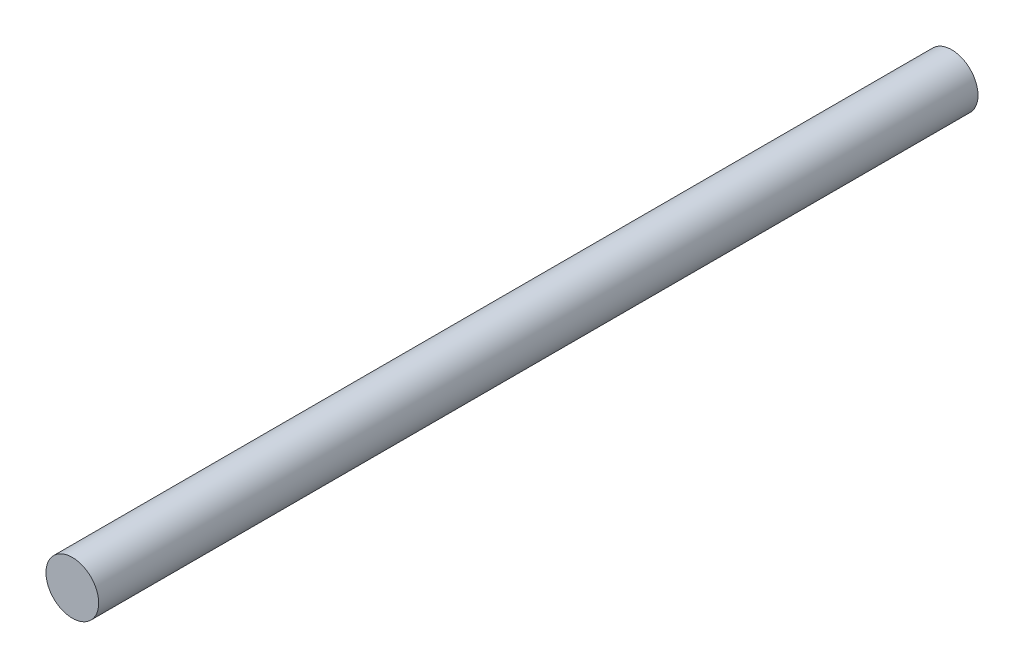
from build123d import *

# Parameters (mm, degrees)
SKETCH_1_R      = 1.5
EXTRUDE_1_DEPTH = 50


with BuildPart() as part:
    # 草图1 → 凸台-拉伸1 (new body)
    with BuildSketch(Plane.XY):
        Circle(SKETCH_1_R)
    extrude(amount=-EXTRUDE_1_DEPTH)


solid = part.part
